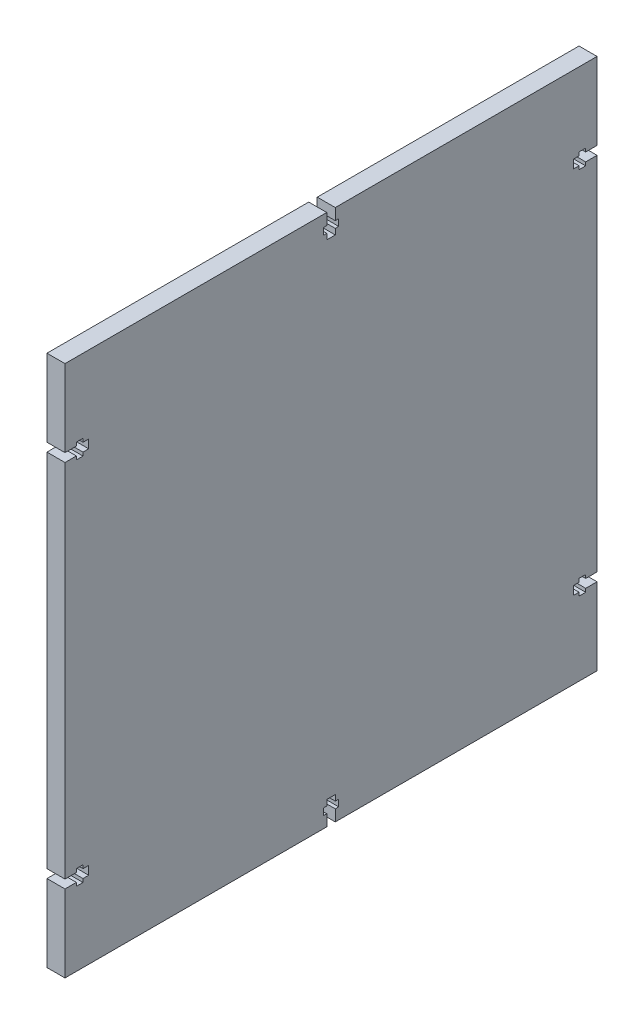
from build123d import *

# Parameters (mm, degrees)
SKETCH1_W           = 187.3
SKETCH1_H           = 187.3
BOSS_EXTRUDE1_DEPTH = 6.35
CUT_EXTRUDE2_DEPTH  = 7.35


with BuildPart() as part:
    # Sketch1 → Boss-Extrude1 (new body)
    with BuildSketch(Plane(origin=(0, 0, 0), x_dir=(0, 0, -1), z_dir=(1, 0, 0))):
        Rectangle(SKETCH1_W, SKETCH1_H)
    extrude(amount=BOSS_EXTRUDE1_DEPTH)

    # Sketch3 → Cut-Extrude2 (cut, through all)
    with BuildSketch(Plane(origin=(6.35, 0, 0), x_dir=(0, 0, -1), z_dir=(1, 0, 0))):
        Polygon((-93.65, 66.5), (-89.65, 66.5), (-89.65, 67.71), (-87.3, 67.71), (-87.3, 66.5), (-85.3, 66.5), (-85.3, 63.5), (-87.3, 63.5), (-87.3, 62.29), (-89.65, 62.29), (-89.65, 63.5), (-93.65, 63.5), align=None)
        Polygon((-87.3, -63.5), (-87.3, -62.29), (-89.65, -62.29), (-89.65, -63.5), (-93.65, -63.5), (-93.65, -66.5), (-89.65, -66.5), (-89.65, -67.71), (-87.3, -67.71), (-87.3, -66.5), (-85.3, -66.5), (-85.3, -63.5), align=None)
        Polygon((93.65, -66.5), (89.65, -66.5), (89.65, -67.71), (87.3, -67.71), (87.3, -66.5), (85.3, -66.5), (85.3, -63.5), (87.3, -63.5), (87.3, -62.29), (89.65, -62.29), (89.65, -63.5), (93.65, -63.5), align=None)
        Polygon((87.3, 63.5), (87.3, 62.29), (89.65, 62.29), (89.65, 63.5), (93.65, 63.5), (93.65, 66.5), (89.65, 66.5), (89.65, 67.71), (87.3, 67.71), (87.3, 66.5), (85.3, 66.5), (85.3, 63.5), align=None)
        Polygon((-1.5, 93.65), (-1.5, 89.65), (-2.71, 89.65), (-2.71, 87.3), (-1.5, 87.3), (-1.5, 85.3), (1.5, 85.3), (1.5, 87.3), (2.71, 87.3), (2.71, 89.65), (1.5, 89.65), (1.5, 93.65), align=None)
        Polygon((-2.71, -87.3), (-1.5, -87.3), (-1.5, -85.3), (1.5, -85.3), (1.5, -87.3), (2.71, -87.3), (2.71, -89.65), (1.5, -89.65), (1.5, -93.65), (-1.5, -93.65), (-1.5, -89.65), (-2.71, -89.65), align=None)
    extrude(amount=-CUT_EXTRUDE2_DEPTH, mode=Mode.SUBTRACT)


solid = part.part
